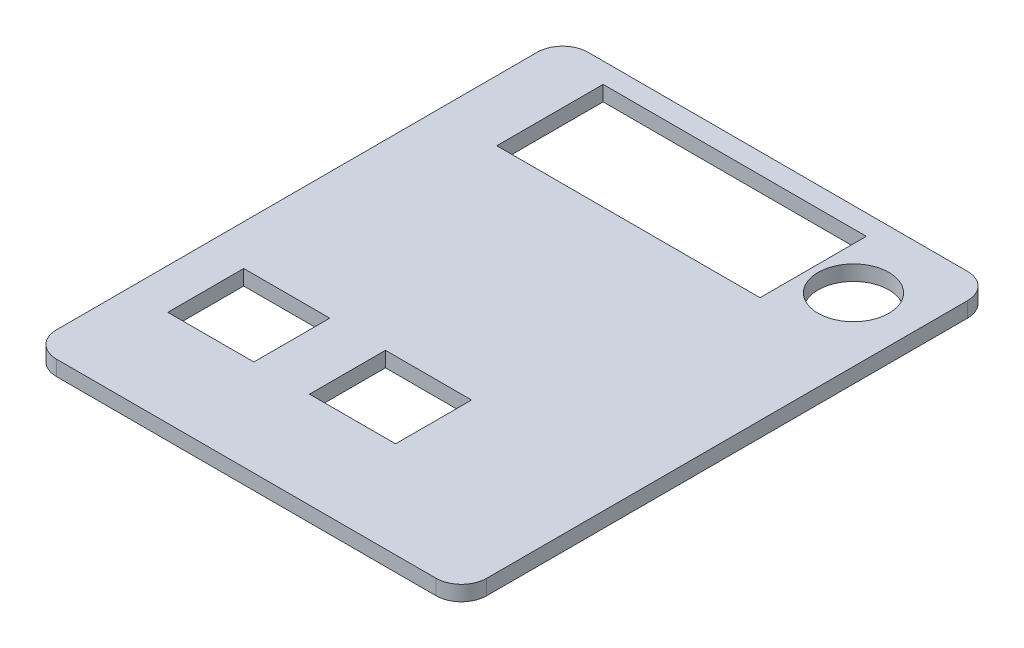
from build123d import *

# Parameters (mm, degrees)
SKETCH1_W           = 85
SKETCH1_H           = 105
BOSS_EXTRUDE1_DEPTH = 3
SKETCH2_W           = 17
SKETCH2_H           = 15
CUT_EXTRUDE1_DEPTH  = 10
FILLET1_R           = 5
SKETCH3_W           = 52
SKETCH3_H           = 21
CUT_EXTRUDE2_DEPTH  = 10
SKETCH4_R           = 7
CUT_EXTRUDE3_DEPTH  = 10


with BuildPart() as part:
    # Sketch1 → Boss-Extrude1 (new body)
    with BuildSketch(Plane(origin=(0, 0, 0), x_dir=(1, 0, 0), z_dir=(0, 1, 0))):
        Rectangle(SKETCH1_W, SKETCH1_H)
    extrude(amount=BOSS_EXTRUDE1_DEPTH)

    # Sketch2 → Cut-Extrude1 (cut)
    with BuildSketch(Plane(origin=(0, 3, 0), x_dir=(1, 0, 0), z_dir=(0, 1, 0))):
        with Locations((-26, -26)):
            Rectangle(SKETCH2_W, SKETCH2_H)
        with Locations((2, -26)):
            Rectangle(SKETCH2_W, SKETCH2_H)
    extrude(amount=-CUT_EXTRUDE1_DEPTH, mode=Mode.SUBTRACT)

    # Fillet1
    fillet1_edges = [part.edges().sort_by_distance(p)[0] for p in [
        (42.5, 1.5, 52.5),
        (-42.5, 1.5, 52.5),
        (-42.5, 1.5, -52.5),
        (42.5, 1.5, -52.5),
    ]]
    fillet(fillet1_edges, radius=FILLET1_R)

    # Sketch3 → Cut-Extrude2 (cut)
    with BuildSketch(Plane(origin=(0, 3, 0), x_dir=(1, 0, 0), z_dir=(0, 1, 0))):
        with Locations((-4.5, 38)):
            Rectangle(SKETCH3_W, SKETCH3_H)
    extrude(amount=-CUT_EXTRUDE2_DEPTH, mode=Mode.SUBTRACT)

    # Sketch4 → Cut-Extrude3 (cut)
    with BuildSketch(Plane(origin=(0, 3, 0), x_dir=(1, 0, 0), z_dir=(0, 1, 0))):
        with Locations(Location((29.897939867, 37.565399996, 0), (0, 0, 270))):
            Circle(SKETCH4_R)
    extrude(amount=-CUT_EXTRUDE3_DEPTH, mode=Mode.SUBTRACT)


solid = part.part
